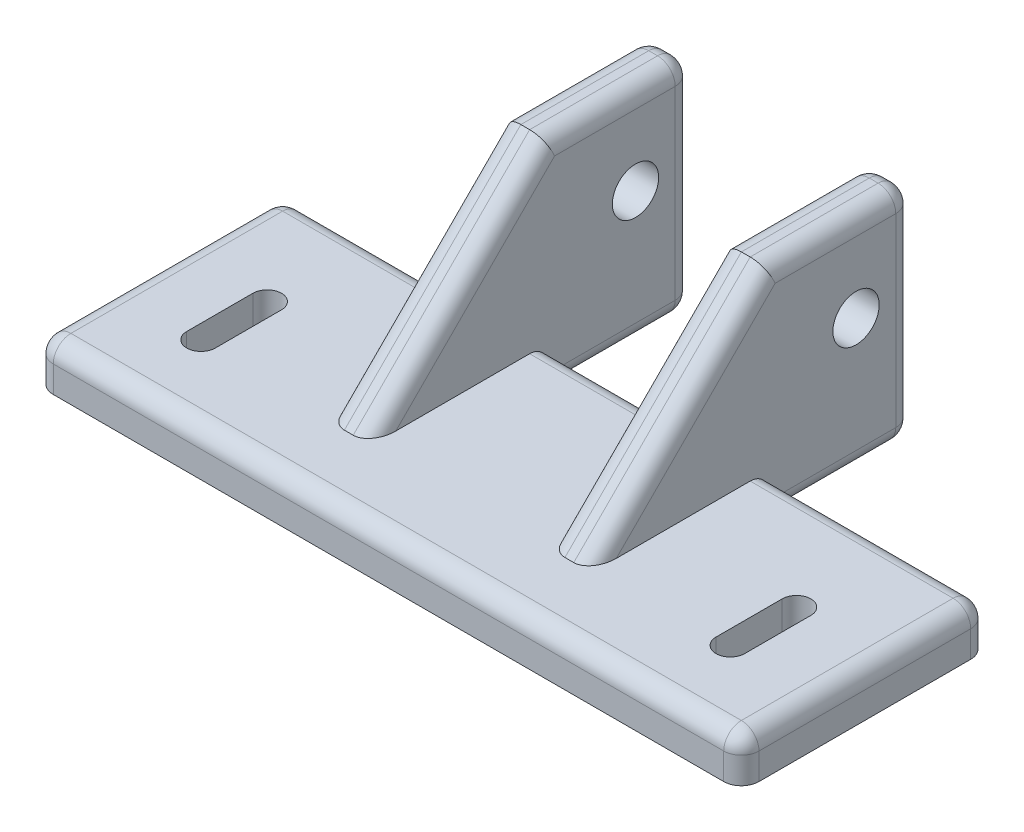
from build123d import *

# Parameters (mm, degrees)
BOSS_EXTRUDE1_START            = 10
SKETCH1_W                      = 16.5
SKETCH1_H                      = 20
SKETCH1_R                      = 2.625
BOSS_EXTRUDE1_DEPTH            = 5
BOSS_EXTRUDE2_START            = -10
SKETCH1_3_W                    = 16.5
SKETCH1_3_H                    = 20
SKETCH1_3_R                    = 2.625
BOSS_EXTRUDE2_DEPTH            = 5
BOSS_EXTRUDE3_START            = -15
SKETCH1_4_W                    = 16.5
SKETCH1_4_H                    = 5
SKETCH1_4_W_2                  = 28
BOSS_EXTRUDE3_DEPTH            = 30
SKETCH2_W                      = 25
SKETCH2_H                      = 28
BOSS_EXTRUDE4_DEPTH            = 5
CUT_EXTRUDE1_REACH             = 59.175
SKETCH1_6_W                    = 16.5
SKETCH1_6_H                    = 5
CUT_EXTRUDE1_DIRECTION_2_REACH = 59.175
BOSS_EXTRUDE5_START            = 10
BOSS_EXTRUDE5_DEPTH            = 5
BOSS_EXTRUDE6_START            = -10
BOSS_EXTRUDE6_DEPTH            = 5
FILLET1_R                      = 2


with BuildPart() as part:
    # Sketch1 → Boss-Extrude1 (new body)
    with BuildSketch(Plane(origin=(0, 0, 0), x_dir=(0, 0, -1), z_dir=(1, 0, 0)).offset(BOSS_EXTRUDE1_START)):
        with Locations((-1.75, 0)):
            Rectangle(SKETCH1_W, SKETCH1_H)
        Circle(SKETCH1_R, mode=Mode.SUBTRACT)
    extrude(amount=BOSS_EXTRUDE1_DEPTH)



with BuildPart() as body_2:
    # Sketch1_3 → Boss-Extrude2 (new body)
    with BuildSketch(Plane(origin=(0, 0, 0), x_dir=(0, 0, -1), z_dir=(1, 0, 0)).offset(BOSS_EXTRUDE2_START)):
        with Locations((-1.75, 0)):
            Rectangle(SKETCH1_3_W, SKETCH1_3_H)
        Circle(SKETCH1_3_R, mode=Mode.SUBTRACT)
    extrude(amount=-BOSS_EXTRUDE2_DEPTH)


with BuildPart() as part_1:
    add(part.part)

    add(body_2.part)  # Boss-Extrude3 merges body 2
    # Sketch1_4 → Boss-Extrude3 (add)
    with BuildSketch(Plane(origin=(0, 0, 0), x_dir=(0, 0, -1), z_dir=(1, 0, 0)).offset(BOSS_EXTRUDE3_START)):
        with Locations((-1.75, -12.5)):
            Rectangle(SKETCH1_4_W, SKETCH1_4_H)
        with Locations((-24, -12.5)):
            Rectangle(SKETCH1_4_W_2, SKETCH1_4_H)
    extrude(amount=BOSS_EXTRUDE3_DEPTH)

    # Sketch2 → Boss-Extrude4 (add)
    with BuildSketch(Plane(origin=(0, -10, 0), x_dir=(1, 0, 0), z_dir=(0, 1, 0))):
        with Locations((-27.5, -24)):
            Rectangle(SKETCH2_W, SKETCH2_H)
        with BuildLine():
            Line((-31.625, -29.25), (-31.625, -21.75))
            ThreePointArc((-31.625, -21.75), (-30, -20.125), (-28.375, -21.75))
            Line((-28.375, -21.75), (-28.375, -29.25))
            ThreePointArc((-28.375, -29.25), (-30, -30.875), (-31.625, -29.25))
        make_face(mode=Mode.SUBTRACT)
        with Locations((27.5, -24)):
            Rectangle(SKETCH2_W, SKETCH2_H)
        with BuildLine():
            Line((31.625, -29.25), (31.625, -21.75))
            ThreePointArc((31.625, -21.75), (30, -20.125), (28.375, -21.75))
            Line((28.375, -21.75), (28.375, -29.25))
            ThreePointArc((28.375, -29.25), (30, -30.875), (31.625, -29.25))
        make_face(mode=Mode.SUBTRACT)
    extrude(amount=-BOSS_EXTRUDE4_DEPTH)

    # Cut-Extrude1: up to this face of the body (flat: up to its plane)
    cut_extrude1_end = Plane(part_1.part.faces().sort_by_distance((10, 0, -6.240722157))[0])
    # Sketch1_6 → Cut-Extrude1 (cut, up to the picked face)
    with BuildSketch(Plane(origin=(0, 0, 0), x_dir=(0, 0, -1), z_dir=(1, 0, 0)), mode=Mode.PRIVATE) as cut_extrude1_sk1:
        with Locations((-1.75, -12.5)):
            Rectangle(SKETCH1_6_W, SKETCH1_6_H)
    cut_extrude1_tool1 = split(extrude(cut_extrude1_sk1.sketch, amount=CUT_EXTRUDE1_REACH, mode=Mode.PRIVATE), bisect_by=cut_extrude1_end, keep=Keep.BOTH, mode=Mode.PRIVATE)
    add(cut_extrude1_tool1.solids().sort_by(Axis((0, -12.5, 1.75), (1, 0, 0)))[0], mode=Mode.SUBTRACT)

    # Cut-Extrude1 direction 2: up to this face of the body (flat: up to its plane)
    cut_extrude1_direction_2_end = Plane(part_1.part.faces().sort_by_distance((-10, 0, -6.240722157))[0])
    # Sketch1_6 → Cut-Extrude1 direction 2 (cut, up to the picked face)
    with BuildSketch(Plane(origin=(0, 0, 0), x_dir=(0, 0, -1), z_dir=(1, 0, 0)), mode=Mode.PRIVATE) as cut_extrude1_direction_2_sk1:
        with Locations((-1.75, -12.5)):
            Rectangle(SKETCH1_6_W, SKETCH1_6_H)
    cut_extrude1_direction_2_tool1 = split(extrude(cut_extrude1_direction_2_sk1.sketch, amount=-CUT_EXTRUDE1_DIRECTION_2_REACH, mode=Mode.PRIVATE), bisect_by=cut_extrude1_direction_2_end, keep=Keep.BOTH, mode=Mode.PRIVATE)
    add(cut_extrude1_direction_2_tool1.solids().sort_by(Axis((0, -12.5, 1.75), (-1, 0, 0)))[0], mode=Mode.SUBTRACT)

    # Sketch1_7 → Boss-Extrude5 (add)
    with BuildSketch(Plane(origin=(0, 0, 0), x_dir=(0, 0, -1), z_dir=(1, 0, 0)).offset(BOSS_EXTRUDE5_START)):
        Polygon((-30, -10), (-10, -10), (-10, 10), align=None)
    extrude(amount=BOSS_EXTRUDE5_DEPTH)

    # Sketch1_8 → Boss-Extrude6 (add)
    with BuildSketch(Plane(origin=(0, 0, 0), x_dir=(0, 0, -1), z_dir=(1, 0, 0)).offset(BOSS_EXTRUDE6_START)):
        Polygon((-30, -10), (-10, -10), (-10, 10), align=None)
    extrude(amount=-BOSS_EXTRUDE6_DEPTH)

    # Fillet1
    fillet1_edges = [part_1.edges().sort_by_distance(p)[0] for p in [
        (12.5, 10, -6.5),
        (-10, 0, 20),
        (-15, 0, 20),
        (12.5, -15, -6.5),
        (-15, -2.5, -6.5),
        (0, -10, 38),
        (-15, -15, 1.75),
        (15, -2.5, -6.5),
        (15, 10, 1.75),
        (-10, 10, 1.75),
        (-10, -2.5, -6.5),
        (-12.5, 10, -6.5),
        (-15, 10, 1.75),
        (15, -15, 1.75),
        (-40, -12.5, 38),
        (-40, -12.5, 10),
        (-40, -10, 24),
        (-27.5, -10, 10),
        (27.5, -10, 10),
        (40, -12.5, 10),
        (40, -10, 24),
        (40, -12.5, 38),
        (10, 10, 1.75),
        (10, -2.5, -6.5),
        (-12.5, -15, -6.5),
        (10, -15, 1.75),
        (0, -10, 10),
        (-10, -15, 1.75),
        (10, 0, 20),
        (15, 0, 20),
    ]]
    fillet(fillet1_edges, radius=FILLET1_R)


solid = part_1.part
